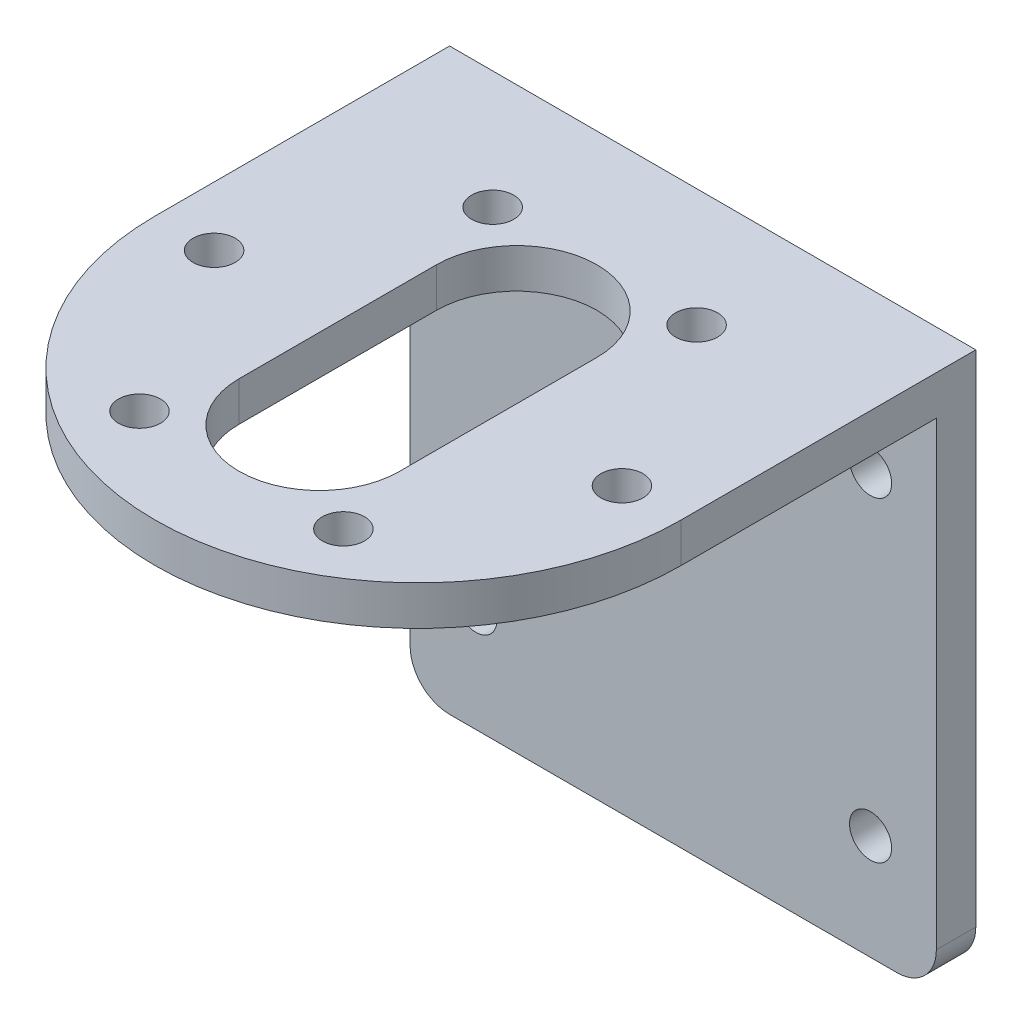
from build123d import *

# Parameters (mm, degrees)
SKETCH_2_W          = 40
SKETCH_2_H          = 41
SKETCH_2_R          = 1.6
EXTRUDE_1_DEPTH     = 44.2
SKETCH_3_W          = 40
SKETCH_3_H          = 38
CUT_EXTRUDE_1_DEPTH = 41.2
FILLET_1_R          = 3
SKETCH_4_R          = 1.6
CUT_EXTRUDE_2_DEPTH = 10


with BuildPart() as part:
    # 草图2 → 凸台-拉伸1 (new body)
    with BuildSketch(Plane.XY):
        with Locations((0.386252919, 6.049930002)):
            Rectangle(SKETCH_2_W, SKETCH_2_H)
        with Locations((-14.613747081, -6.450069998)):
            Circle(SKETCH_2_R, mode=Mode.SUBTRACT)
        with Locations((15.386252919, -6.450069998)):
            Circle(SKETCH_2_R, mode=Mode.SUBTRACT)
        with Locations((-14.613747081, 17.549930002)):
            Circle(SKETCH_2_R, mode=Mode.SUBTRACT)
        with Locations((15.386252919, 17.549930002)):
            Circle(SKETCH_2_R, mode=Mode.SUBTRACT)
    extrude(amount=EXTRUDE_1_DEPTH)

    # 草图3 → 切除-拉伸1 (cut)
    with BuildSketch(Plane.XY.offset(44.2)):
        with Locations((0.386252919, 4.549930002)):
            Rectangle(SKETCH_3_W, SKETCH_3_H)
    extrude(amount=-CUT_EXTRUDE_1_DEPTH, mode=Mode.SUBTRACT)

    # 圆角1
    fillet_1_edges = [part.edges().sort_by_distance(p)[0] for p in [
        (20.386252919, -14.450069998, 1.5),
        (-19.613747081, -14.450069998, 1.5),
    ]]
    fillet(fillet_1_edges, radius=FILLET_1_R)

    # 草图4 → 切除-拉伸2 (cut)
    with BuildSketch(Plane.XZ.offset(-23.549930002)):
        with Locations((-7.363747081, 35.823393759)):
            Circle(SKETCH_4_R)
        with Locations((8.136252919, 35.823393759)):
            Circle(SKETCH_4_R)
        with Locations((15.886252919, 22.4)):
            Circle(SKETCH_4_R)
        with Locations((8.136252919, 8.976606241)):
            Circle(SKETCH_4_R)
        with Locations((-7.363747081, 8.976606241)):
            Circle(SKETCH_4_R)
        with Locations((-15.113747081, 22.4)):
            Circle(SKETCH_4_R)
        with BuildLine():
            Line((-19.613747081, 44.2), (20.386252919, 44.2))
            Line((20.386252919, 44.2), (20.386252919, 22.4))
            ThreePointArc((20.386252919, 22.4), (0.386252919, 42.4), (-19.613747081, 22.4))
            Line((-19.613747081, 22.4), (-19.613747081, 44.2))
        make_face()
        with BuildLine():
            Line((-5.713747081, 14.9), (-5.713747081, 29.9))
            ThreePointArc((-5.713747081, 29.9), (0.386252919, 36), (6.486252919, 29.9))
            Line((6.486252919, 29.9), (6.486252919, 14.9))
            ThreePointArc((6.486252919, 14.9), (0.386252919, 8.8), (-5.713747081, 14.9))
        make_face()
    extrude(amount=-CUT_EXTRUDE_2_DEPTH, mode=Mode.SUBTRACT)


solid = part.part
